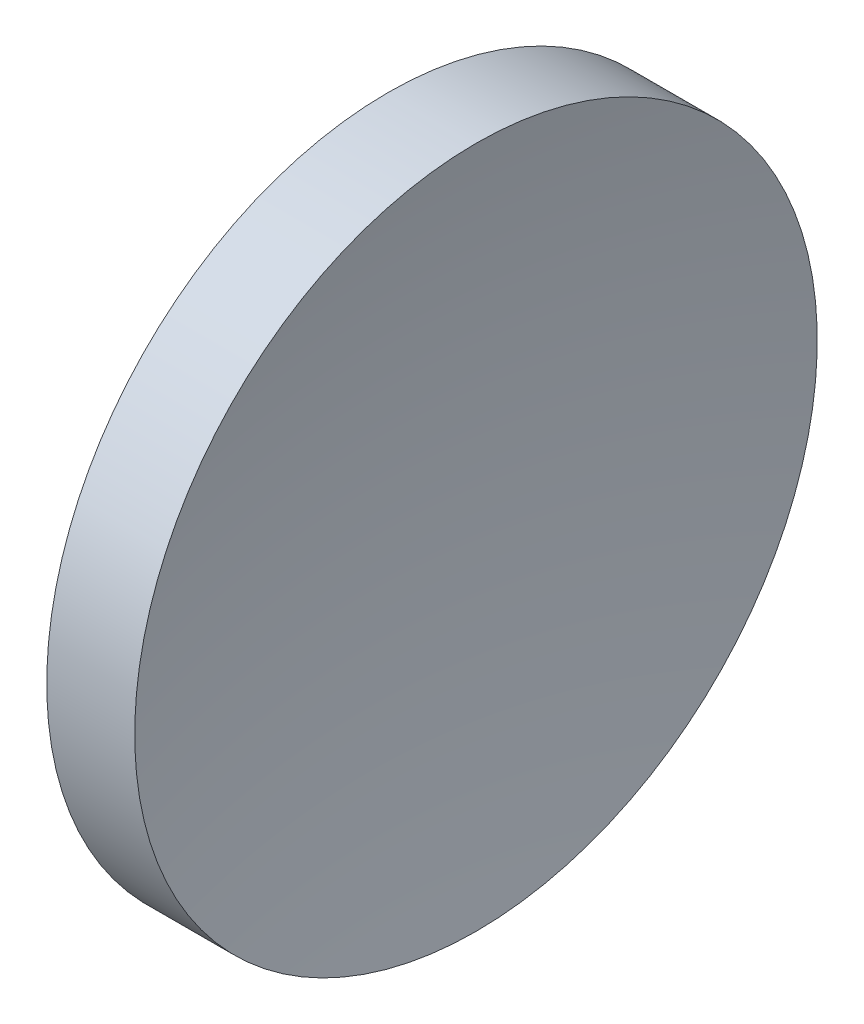
from build123d import *


with BuildPart() as part:
    # 草图1 → 旋转1 (revolve)
    with BuildSketch(Plane.XY, mode=Mode.PRIVATE) as revolve_1_sk:
        with BuildLine():
            Line((57.358190158, 32.578725913), (57.358190158, 45.078725913))
            Line((57.358190158, 45.078725913), (60.580478006, 45.078725913))
            ThreePointArc((60.580478006, 45.078725913), (59.664592702, 38.858524449), (59.358190193, 32.578725913))
            Line((59.358190193, 32.578725913), (57.358190158, 32.578725913))
        make_face()
    revolve(revolve_1_sk.sketch.rotate(Axis((55.007394624, 32.578725913, 0), (1, 0, 0)), 180), axis=Axis((55.007394624, 32.578725913, 0), (1, 0, 0)))  # turned: the seam where the file's is


solid = part.part
